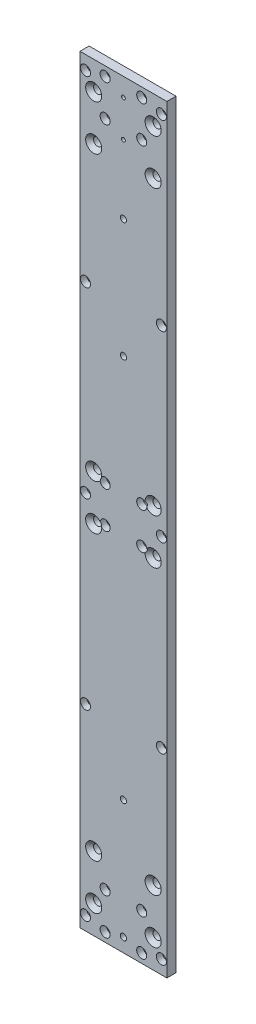
from build123d import *

# Parameters (mm, degrees)
SKETCH_1_W                  = 95
SKETCH_1_H                  = 830
EXTRUDE_1_DEPTH             = 5
HOLE_WIZARD_1_D             = 6.6
HOLE_WIZARD_1_CBORE_D       = 11
HOLE_WIZARD_1_CBORE_DEPTH   = 6.8
HOLE_WIZARD_M8_1_D          = 6.8
HOLE_WIZARD_M8_2_D          = 6.8
HOLE_WIZARD_2_D             = 6.6
HOLE_WIZARD_2_DEPTH         = 10.001
HOLE_WIZARD_2_CBORE_D       = 11
HOLE_WIZARD_2_CBORE_DEPTH   = 6.8
HOLE_WIZARD_M5_1_D          = 4.2
HOLE_WIZARD_1_2_D           = 9
HOLE_WIZARD_1_2_CSINK_D     = 17.6
HOLE_WIZARD_1_2_CSINK_ANGLE = 90


with BuildPart() as part:
    # 草图1 → 凸台-拉伸1 (new body, symmetric)
    with BuildSketch(Plane.XY):
        Rectangle(SKETCH_1_W, SKETCH_1_H)
    extrude(amount=EXTRUDE_1_DEPTH, both=True)

    # Hole Wizard 1 (through all)
    with Locations(Plane(origin=(-20, -365, 5), x_dir=(1, 0, 0), z_dir=(0, 0, 1))):
        with Locations((0, 0), (40, 0), (40, -40), (0, -40), (0, 385), (40, 385), (40, 345), (0, 345), (0, 770), (40, 770), (40, 730), (0, 730)):
            CounterBoreHole(HOLE_WIZARD_1_D / 2, HOLE_WIZARD_1_CBORE_D / 2, HOLE_WIZARD_1_CBORE_DEPTH)

    # M8 螺纹孔1 (through all)
    with Locations(Plane(origin=(0, -400, 5), x_dir=(1, 0, 0), z_dir=(0, 0, 1))):
        with Locations((0, 0), (0, 130)):
            Hole(HOLE_WIZARD_M8_1_D / 2)

    # M8 螺纹孔2 (through all)
    with Locations(Plane(origin=(0, 280, 5), x_dir=(1, 0, 0), z_dir=(0, 0, 1))):
        with Locations((0, 0), (0, -130)):
            Hole(HOLE_WIZARD_M8_2_D / 2)

    # 打孔尺寸(%根据)内六角圆柱头螺钉的类型2
    with Locations(Plane(origin=(41.5, 400, 5), x_dir=(1, 0, 0), z_dir=(0, 0, 1))):
        with Locations((0, 0), (0, -200), (0, -400), (0, -600), (0, -800)):
            hole_wizard_2 = CounterBoreHole(HOLE_WIZARD_2_D / 2, HOLE_WIZARD_2_CBORE_D / 2, HOLE_WIZARD_2_CBORE_DEPTH, depth=HOLE_WIZARD_2_DEPTH)

    # 镜向1: 打孔尺寸(%根据)内六角圆柱头螺钉的类型2 across plane
    add(hole_wizard_2.mirror(Plane(origin=(0, 0, 0), x_dir=(0, 0, 1), z_dir=(1, 0, 0))), mode=Mode.SUBTRACT)

    # M5 螺纹孔1 (through all)
    with Locations(Plane(origin=(0, 395, 5), x_dir=(1, 0, 0), z_dir=(0, 0, 1))):
        with Locations((0, 0), (0, -40)):
            Hole(HOLE_WIZARD_M5_1_D / 2)

    # Hole Wizard 1 2 (through all)
    with Locations(Plane(origin=(-32.5, 24.75, 5), x_dir=(1, 0, 0), z_dir=(0, 0, 1))):
        with Locations((0, 0), (65, 0), (65, -49.5), (0, -49.5), (0, 359.5), (65, 359.5), (65, 310), (0, 310), (0, -359.5), (65, -359.5), (65, -409), (0, -409)):
            CounterSinkHole(HOLE_WIZARD_1_2_D / 2, HOLE_WIZARD_1_2_CSINK_D / 2, counter_sink_angle=HOLE_WIZARD_1_2_CSINK_ANGLE)


solid = part.part
